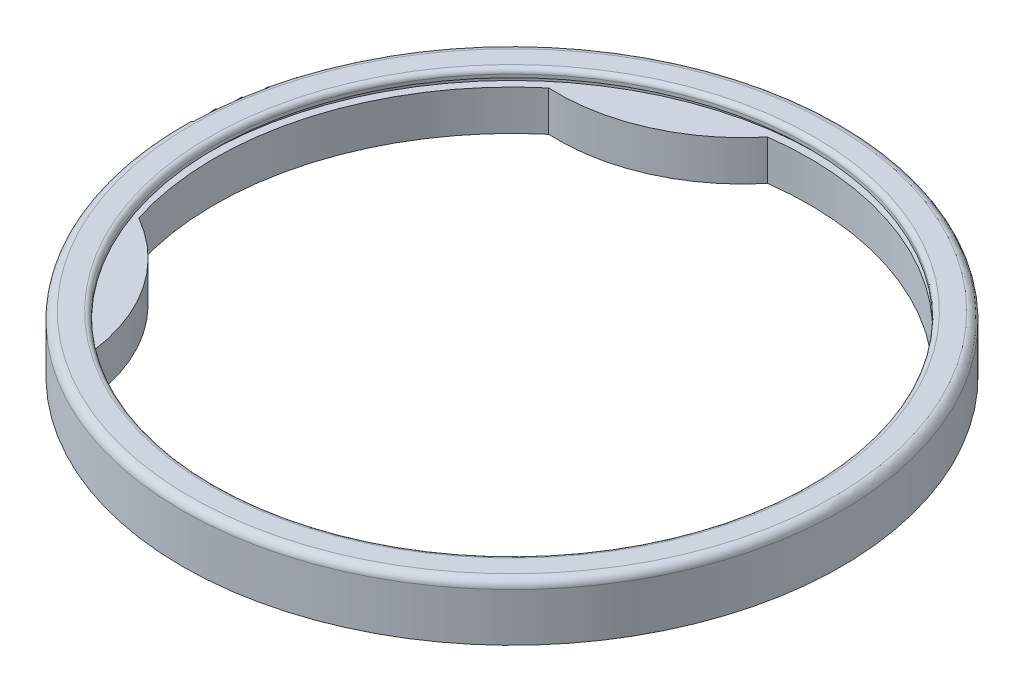
from build123d import *

# Parameters (mm, degrees)
FILLET1_R           = 5
FILLET2_R           = 3
BOSS_EXTRUDE1_DEPTH = 25
CUT_EXTRUDE3_START  = -5
SKETCH24_R          = 10
CUT_EXTRUDE3_DEPTH  = 21


with BuildPart() as part:
    # Sketch2 → Revolve1 (revolve)
    with BuildSketch(Plane(origin=(0, 0, 0), x_dir=(0, 0, -1), z_dir=(1, 0, 0))):
        Polygon((-185, -25), (-205, -25), (-205, 10), (-185, 10), (-185, 5), (-190, 5), (-190, 0), (-185, 0), align=None)
    revolve(axis=Axis((0, 0, 0), (0, 1, 0)))

    # Fillet1
    fillet1_edges = [part.edges().sort_by_distance(p)[0] for p in [
        (0, 10, -205),
    ]]
    fillet(fillet1_edges, radius=FILLET1_R)

    # Fillet2
    fillet2_edges = [part.edges().sort_by_distance(p)[0] for p in [
        (0, 10, -185),
    ]]
    fillet(fillet2_edges, radius=FILLET2_R)

    # Sketch15 → Boss-Extrude1 (add)
    with BuildSketch(Plane(origin=(0, 0, 0), x_dir=(1, 0, 0), z_dir=(0, 1, 0))):
        with BuildLine():
            ThreePointArc((-118.887266817, 141.742081926), (-66.69307667, 151.357832715), (-24.375030373, 183.387180289))
            ThreePointArc((-24.375030373, 183.387180289), (-74.596246578, 169.293827402), (-118.887266817, 141.742081926))
        make_face()
        with BuildLine():
            ThreePointArc((-118.944143978, -141.694356321), (-137.477235911, -91.962870803), (-176.368437347, -55.849568556))
            ThreePointArc((-176.368437347, -55.849568556), (-153.768371484, -102.860526594), (-118.944143978, -141.694356321))
        make_face()
    extrude(amount=-BOSS_EXTRUDE1_DEPTH)

    # Sketch24 → Cut-Extrude3 (cut, through all)
    with BuildSketch(Plane(origin=(0, 0, 0), x_dir=(1, 0, 0), z_dir=(0, 1, 0)).offset(CUT_EXTRUDE3_START)):
        with Locations((-74.596246578, 169.293827402)):
            Circle(SKETCH24_R)
        with Locations((-153.768371484, -102.860526594)):
            Circle(SKETCH24_R)
    extrude(amount=-CUT_EXTRUDE3_DEPTH, mode=Mode.SUBTRACT)


solid = part.part
